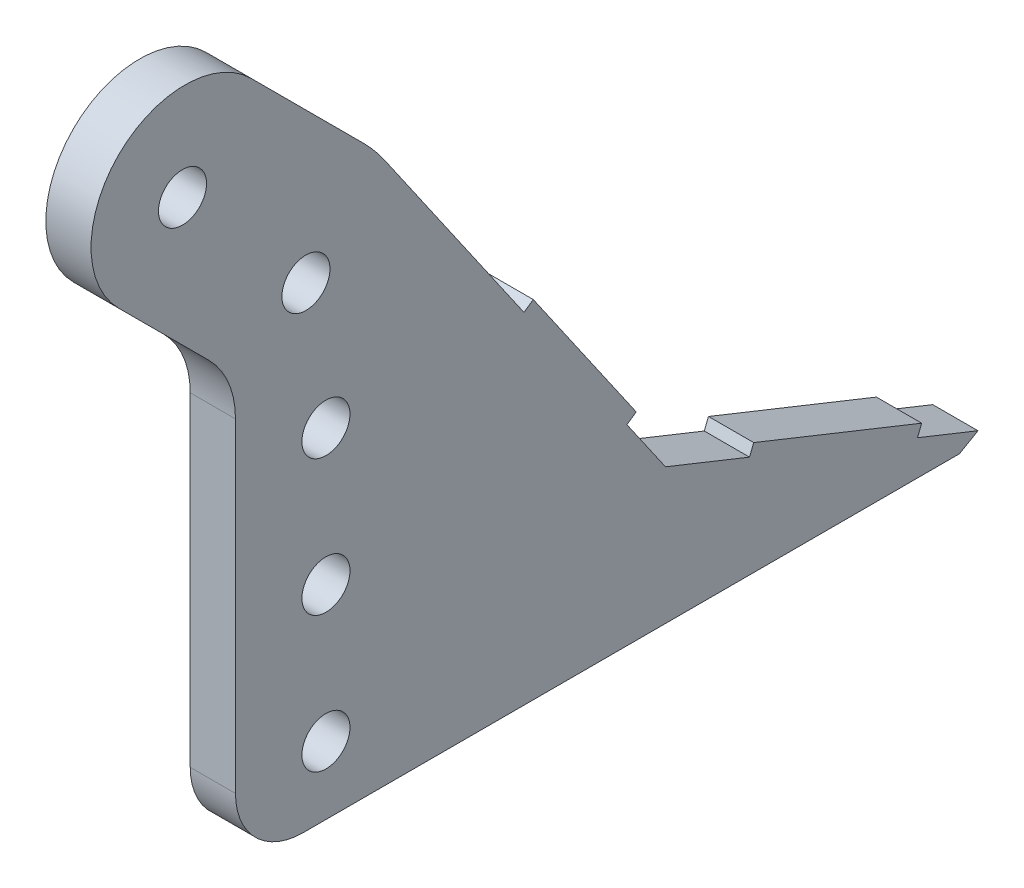
from build123d import *

# Parameters (mm, degrees)
SKETCH1_R                   = 19.05
BOSS_EXTRUDE1_DEPTH         = 12.7
FILLET1_R                   = 25.4
FILLET2_R                   = 50.8
F_1_2_CLEARANCE_HOLE1_D     = 13.49248
F_1_2_CLEARANCE_HOLE1_DEPTH = 38.1
F_1_2_CLEARANCE_HOLE1_TIP   = 4.053549943
SKETCH4_R                   = 19.05
CUT_EXTRUDE1_DEPTH          = 13.7
BOSS_EXTRUDE2_DEPTH         = 12.7
BOSS_EXTRUDE3_DEPTH         = 12.7
FILLET3_R                   = 19.05
CHAMFER1_SIZE               = 12.7
CHAMFER1_SIZE2              = 8.080195177


with BuildPart() as part:
    # Sketch1 → Boss-Extrude1 (new body)
    with BuildSketch(Plane(origin=(0, 0, 0), x_dir=(0, 0, -1), z_dir=(1, 0, 0))):
        with BuildLine():
            Line((390.630407277, -109.766978243), (305.29908743, -24.435658396))
            Line((305.29908743, -24.435658396), (12.395871839, 49.264412727))
            ThreePointArc((12.395871839, 49.264412727), (-49.470959365, 11.544010545), (-10.688712274, -49.662777107))
            Line((-10.688712274, -49.662777107), (281.610658396, -75.235658396))
            Line((281.610658396, -75.235658396), (339.725, -133.35))
            Line((339.725, -133.35), (339.725, -254))
            Line((339.725, -254), (390.630407277, -254))
            Line((390.630407277, -254), (390.630407277, -109.766978243))
        make_face()
        Circle(SKETCH1_R, mode=Mode.SUBTRACT)
    extrude(amount=BOSS_EXTRUDE1_DEPTH)

    # Fillet1
    fillet1_edges = [part.edges().sort_by_distance(p)[0] for p in [
        (6.35, -133.35, -339.725),
        (6.35, -75.235658396, -281.610658396),
    ]]
    fillet(fillet1_edges, radius=FILLET1_R)

    # Fillet2
    fillet2_edges = [part.edges().sort_by_distance(p)[0] for p in [
        (6.35, -24.435658396, -305.29908743),
        (6.35, -109.766978243, -390.630407277),
    ]]
    fillet(fillet2_edges, radius=FILLET2_R)

    # 1/2 Clearance Hole1
    with Locations(Plane(origin=(12.7, 0, 0), x_dir=(0, 0, -1), z_dir=(1, 0, 0))):
        with Locations((365.125, -234.95), (365.125, -196.85), (365.125, -158.75), (359.5071206, -120.65), (324.846024484, -82.55)):
            Hole(F_1_2_CLEARANCE_HOLE1_D / 2, depth=F_1_2_CLEARANCE_HOLE1_DEPTH)
            with Locations((0, 0, -(F_1_2_CLEARANCE_HOLE1_DEPTH + F_1_2_CLEARANCE_HOLE1_TIP / 2))):  # 118° drill point
                Cone(0, F_1_2_CLEARANCE_HOLE1_D / 2, F_1_2_CLEARANCE_HOLE1_TIP, mode=Mode.SUBTRACT)

    # Sketch4 → Cut-Extrude1 (cut, through all)
    with BuildSketch(Plane(origin=(12.7, 0, 0), x_dir=(0, 0, -1), z_dir=(1, 0, 0))):
        with BuildLine():
            Line((288.147750244, -81.772750244), (306.885512242, -100.510512242))
            ThreePointArc((306.885512242, -100.510512242), (306.885512242, -63.266297725), (344.129726759, -63.266297725))
            Line((344.129726759, -63.266297725), (315.219181895, -34.355752861))
            ThreePointArc((315.219181895, -34.355752861), (304.360921026, -26.089699144), (291.69402925, -21.012364618))
            Line((291.69402925, -21.012364618), (12.395871839, 49.264412727))
            ThreePointArc((12.395871839, 49.264412727), (-49.470959365, 11.544010545), (-10.688712274, -49.662777107))
            Line((-10.688712274, -49.662777107), (272.400993868, -74.429917155))
            ThreePointArc((272.400993868, -74.429917155), (280.92174185, -76.713044696), (288.147750244, -81.772750244))
        make_face()
        Circle(SKETCH4_R, mode=Mode.SUBTRACT)
    extrude(amount=-CUT_EXTRUDE1_DEPTH, mode=Mode.SUBTRACT)

    # Sketch5 → Boss-Extrude2 (add)
    with BuildSketch(Plane(origin=(12.7, 0, 0), x_dir=(0, 0, -1), z_dir=(1, 0, 0))):
        with BuildLine():
            Line((390.630407277, -254), (555.730407277, -254))
            Line((555.730407277, -254), (460.480407277, -215.9))
            Line((460.480407277, -215.9), (381.605516519, -101.904352022))
            ThreePointArc((381.605516519, -101.904352022), (388.321723765, -115.668610267), (390.630407277, -130.809027211))
            Line((390.630407277, -130.809027211), (390.630407277, -254))
        make_face()
    extrude(amount=-BOSS_EXTRUDE2_DEPTH)

    # Sketch6 → Boss-Extrude3 (add)
    with BuildSketch(Plane(origin=(12.7, 0, 0), x_dir=(0, 0, -1), z_dir=(1, 0, 0))):
        Polygon((449.641154081, -200.234334034), (452.252098409, -198.427791835), (423.347423219, -156.652682593), (420.736478891, -158.459224792), align=None)
        Polygon((484.063715226, -225.333323179), (485.242880623, -222.385409686), (532.40949652, -241.252056045), (531.230331123, -244.199969538), align=None)
    extrude(amount=-BOSS_EXTRUDE3_DEPTH)

    # Fillet3
    fillet3_edges = [part.edges().sort_by_distance(p)[0] for p in [
        (6.35, -254, -339.725),
    ]]
    fillet(fillet3_edges, radius=FILLET3_R)

    # Chamfer1
    chamfer1_edges = [part.edges().sort_by_distance(p)[0] for p in [
        (6.35, -254, -555.730407277),
    ]]
    chamfer1_side = [part.faces().sort_by_distance(p)[0] for p in [
        (6.35, -254, -457.252703639),
    ]]
    chamfer(chamfer1_edges, length=CHAMFER1_SIZE, length2=CHAMFER1_SIZE2, reference=chamfer1_side[0])


solid = part.part
